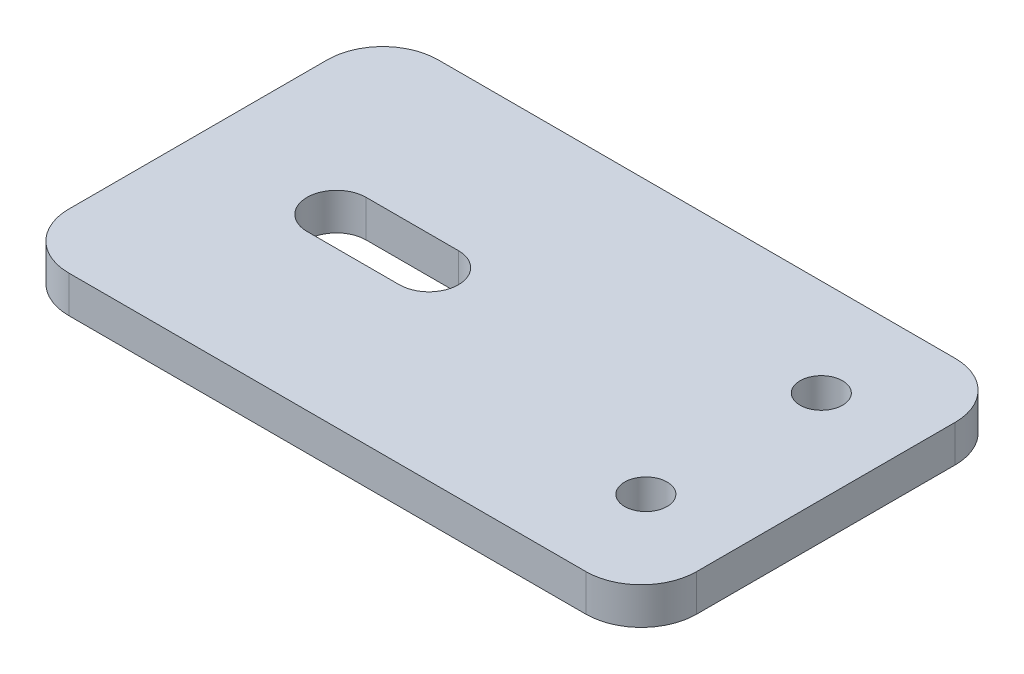
from build123d import *

# Parameters (mm, degrees)
SKETCH_1_R          = 1.6
SKETCH_1_R_2        = 1.15
EXTRUDE_1_DEPTH     = 2
FILLET_2_R          = 3
CUT_EXTRUDE_1_DEPTH = 10


with BuildPart() as part:
    # 草图1 → 凸台-拉伸1 (new body)
    with BuildSketch(Plane(origin=(0, 0, 0), x_dir=(1, 0, 0), z_dir=(0, 1, 0))):
        Polygon((-10, 10), (10, 10), (24, 10), (24, -10), (10, -10), (-10, -10), align=None)
        Circle(SKETCH_1_R, mode=Mode.SUBTRACT)
        with Locations((19, -4.75)):
            Circle(SKETCH_1_R_2, mode=Mode.SUBTRACT)
        with Locations((19, 4.75)):
            Circle(SKETCH_1_R_2, mode=Mode.SUBTRACT)
    extrude(amount=EXTRUDE_1_DEPTH)

    # 圆角2
    fillet_2_edges = [part.edges().sort_by_distance(p)[0] for p in [
        (-10, 1, -10),
        (24, 1, -10),
        (24, 1, 10),
        (-10, 1, 10),
    ]]
    fillet(fillet_2_edges, radius=FILLET_2_R)

    # 草图2 → 切除-拉伸1 (cut)
    with BuildSketch(Plane(origin=(0, 2, 0), x_dir=(1, 0, 0), z_dir=(0, 1, 0))):
        with BuildLine():
            Line((2.5, -1.6), (-2.5, -1.6))
            ThreePointArc((-2.5, -1.6), (-4.1, 0), (-2.5, 1.6))
            Line((-2.5, 1.6), (2.5, 1.6))
            ThreePointArc((2.5, 1.6), (4.1, 0), (2.5, -1.6))
        make_face()
    extrude(amount=-CUT_EXTRUDE_1_DEPTH, mode=Mode.SUBTRACT)


solid = part.part
